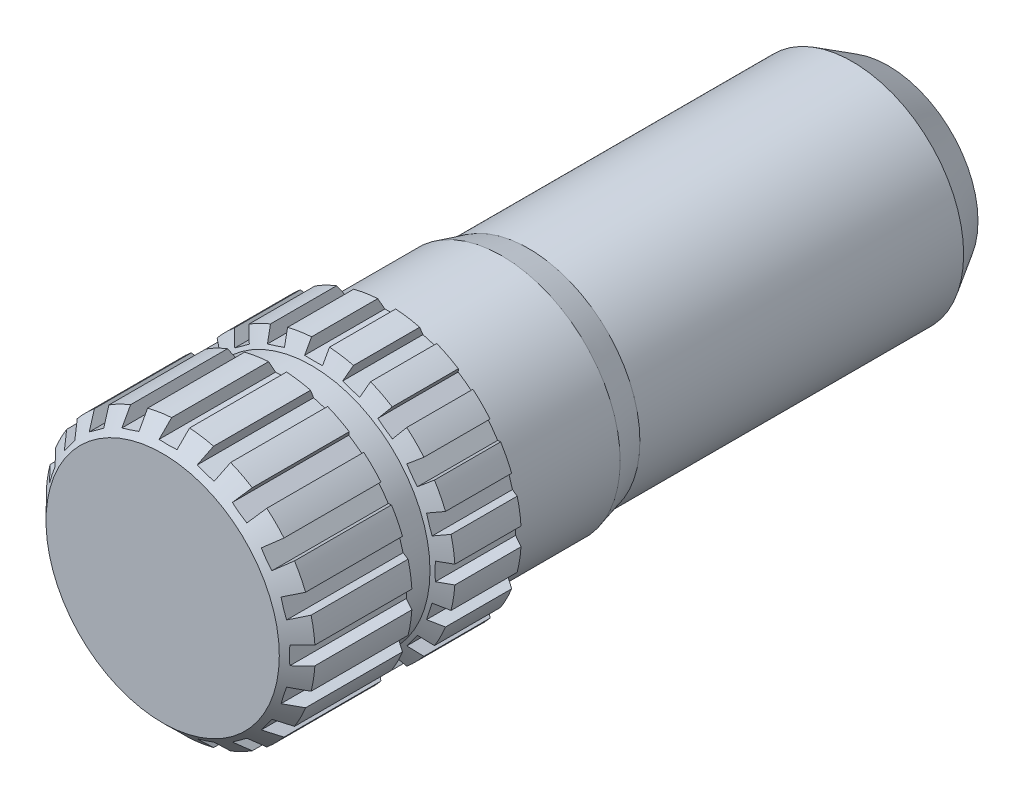
from build123d import *

# Parameters (mm, degrees)
CHAMFER1_SIZE      = 1.27
SKETCH2_OUTSIDE_W  = 32.648
SKETCH2_OUTSIDE_H  = 32.648
CUT_EXTRUDE1_DEPTH = 52.347959


with BuildPart() as part:
    # Sketch1 → Revolve1 (revolve)
    with BuildSketch(Plane(origin=(0, 0, 0), x_dir=(0, 0, -1), z_dir=(1, 0, 0))):
        Polygon((-33.567959, 0), (-33.567959, 9.525), (-25.436281885, 9.525), (-24.801281885, 8.382), (-23.030636116, 8.382), (-22.395636116, 9.525), (-17.713279, 9.525), (-17.057959, 8.382), (-9.573838806, 8.382), (-7.668838806, 7.874), (15.24, 7.874), (17.78, 6.35), (17.78, 0), align=None)
    revolve(axis=Axis((0, 0, -0.29154961), (0, 0, 1)))

    # Chamfer1
    chamfer1_edges = [part.edges().sort_by_distance(p)[0] for p in [
        (0, -9.525, 33.567959),
    ]]
    chamfer(chamfer1_edges, length=CHAMFER1_SIZE)

    # Sketch2 outside → Cut-Extrude1 (cut, through all)
    with BuildSketch(Plane.XY.offset(33.567959)):
        Rectangle(SKETCH2_OUTSIDE_W, SKETCH2_OUTSIDE_H)
        with BuildLine():
            Line((-0.635, 8.614809762), (0.635, 8.614809762))
            Line((0.635, 8.614809762), (0.635, 9.503809762))
            ThreePointArc((0.635, 9.503809762), (1.49003828, 9.407731444), (2.33291784, 9.234885996))
            Line((2.33291784, 9.234885996), (2.058201732, 8.389396753))
            Line((2.058201732, 8.389396753), (3.266043508, 7.99694517))
            Line((3.266043508, 7.99694517), (3.540759616, 8.842434413))
            ThreePointArc((3.540759616, 8.842434413), (4.32425951, 8.486837143), (5.072473428, 8.061987244))
            Line((5.072473428, 8.061987244), (4.549932338, 7.342771136))
            Line((4.549932338, 7.342771136), (5.577383921, 6.596283866))
            Line((5.577383921, 6.596283866), (6.09992501, 7.315499974))
            ThreePointArc((6.09992501, 7.315499974), (6.735192091, 6.735192091), (7.315499974, 6.09992501))
            Line((7.315499974, 6.09992501), (6.596283866, 5.577383921))
            Line((6.596283866, 5.577383921), (7.342771136, 4.549932338))
            Line((7.342771136, 4.549932338), (8.061987244, 5.072473428))
            ThreePointArc((8.061987244, 5.072473428), (8.486837143, 4.32425951), (8.842434413, 3.540759616))
            Line((8.842434413, 3.540759616), (7.99694517, 3.266043508))
            Line((7.99694517, 3.266043508), (8.389396753, 2.058201732))
            Line((8.389396753, 2.058201732), (9.234885996, 2.33291784))
            ThreePointArc((9.234885996, 2.33291784), (9.407731444, 1.49003828), (9.503809762, 0.635))
            Line((9.503809762, 0.635), (8.614809762, 0.635))
            Line((8.614809762, 0.635), (8.614809762, -0.635))
            Line((8.614809762, -0.635), (9.503809762, -0.635))
            ThreePointArc((9.503809762, -0.635), (9.407731444, -1.49003828), (9.234885996, -2.33291784))
            Line((9.234885996, -2.33291784), (8.389396753, -2.058201732))
            Line((8.389396753, -2.058201732), (7.99694517, -3.266043508))
            Line((7.99694517, -3.266043508), (8.842434413, -3.540759616))
            ThreePointArc((8.842434413, -3.540759616), (8.486837143, -4.32425951), (8.061987244, -5.072473428))
            Line((8.061987244, -5.072473428), (7.342771136, -4.549932338))
            Line((7.342771136, -4.549932338), (6.596283866, -5.577383921))
            Line((6.596283866, -5.577383921), (7.315499974, -6.09992501))
            ThreePointArc((7.315499974, -6.09992501), (6.735192091, -6.735192091), (6.09992501, -7.315499974))
            Line((6.09992501, -7.315499974), (5.577383921, -6.596283866))
            Line((5.577383921, -6.596283866), (4.549932338, -7.342771136))
            Line((4.549932338, -7.342771136), (5.072473428, -8.061987244))
            ThreePointArc((5.072473428, -8.061987244), (4.32425951, -8.486837143), (3.540759616, -8.842434413))
            Line((3.540759616, -8.842434413), (3.266043508, -7.99694517))
            Line((3.266043508, -7.99694517), (2.058201732, -8.389396753))
            Line((2.058201732, -8.389396753), (2.33291784, -9.234885996))
            ThreePointArc((2.33291784, -9.234885996), (1.49003828, -9.407731444), (0.635, -9.503809762))
            Line((0.635, -9.503809762), (0.635, -8.614809762))
            Line((0.635, -8.614809762), (-0.635, -8.614809762))
            Line((-0.635, -8.614809762), (-0.635, -9.503809762))
            ThreePointArc((-0.635, -9.503809762), (-1.49003828, -9.407731444), (-2.33291784, -9.234885996))
            Line((-2.33291784, -9.234885996), (-2.058201732, -8.389396753))
            Line((-2.058201732, -8.389396753), (-3.266043508, -7.99694517))
            Line((-3.266043508, -7.99694517), (-3.540759616, -8.842434413))
            ThreePointArc((-3.540759616, -8.842434413), (-4.32425951, -8.486837143), (-5.072473428, -8.061987244))
            Line((-5.072473428, -8.061987244), (-4.549932338, -7.342771136))
            Line((-4.549932338, -7.342771136), (-5.577383921, -6.596283866))
            Line((-5.577383921, -6.596283866), (-6.09992501, -7.315499974))
            ThreePointArc((-6.09992501, -7.315499974), (-6.735192091, -6.735192091), (-7.315499974, -6.09992501))
            Line((-7.315499974, -6.09992501), (-6.596283866, -5.577383921))
            Line((-6.596283866, -5.577383921), (-7.342771136, -4.549932338))
            Line((-7.342771136, -4.549932338), (-8.061987244, -5.072473428))
            ThreePointArc((-8.061987244, -5.072473428), (-8.486837143, -4.32425951), (-8.842434413, -3.540759616))
            Line((-8.842434413, -3.540759616), (-7.99694517, -3.266043508))
            Line((-7.99694517, -3.266043508), (-8.389396753, -2.058201732))
            Line((-8.389396753, -2.058201732), (-9.234885996, -2.33291784))
            ThreePointArc((-9.234885996, -2.33291784), (-9.407731444, -1.49003828), (-9.503809762, -0.635))
            Line((-9.503809762, -0.635), (-8.614809762, -0.635))
            Line((-8.614809762, -0.635), (-8.614809762, 0.635))
            Line((-8.614809762, 0.635), (-9.503809762, 0.635))
            ThreePointArc((-9.503809762, 0.635), (-9.407731444, 1.49003828), (-9.234885996, 2.33291784))
            Line((-9.234885996, 2.33291784), (-8.389396753, 2.058201732))
            Line((-8.389396753, 2.058201732), (-7.99694517, 3.266043508))
            Line((-7.99694517, 3.266043508), (-8.842434413, 3.540759616))
            ThreePointArc((-8.842434413, 3.540759616), (-8.486837143, 4.32425951), (-8.061987244, 5.072473428))
            Line((-8.061987244, 5.072473428), (-7.342771136, 4.549932338))
            Line((-7.342771136, 4.549932338), (-6.596283866, 5.577383921))
            Line((-6.596283866, 5.577383921), (-7.315499974, 6.09992501))
            ThreePointArc((-7.315499974, 6.09992501), (-6.735192091, 6.735192091), (-6.09992501, 7.315499974))
            Line((-6.09992501, 7.315499974), (-5.577383921, 6.596283866))
            Line((-5.577383921, 6.596283866), (-4.549932338, 7.342771136))
            Line((-4.549932338, 7.342771136), (-5.072473428, 8.061987244))
            ThreePointArc((-5.072473428, 8.061987244), (-4.32425951, 8.486837143), (-3.540759616, 8.842434413))
            Line((-3.540759616, 8.842434413), (-3.266043508, 7.99694517))
            Line((-3.266043508, 7.99694517), (-2.058201732, 8.389396753))
            Line((-2.058201732, 8.389396753), (-2.33291784, 9.234885996))
            ThreePointArc((-2.33291784, 9.234885996), (-1.49003828, 9.407731444), (-0.635, 9.503809762))
            Line((-0.635, 9.503809762), (-0.635, 8.614809762))
        make_face(mode=Mode.SUBTRACT)
    extrude(amount=-CUT_EXTRUDE1_DEPTH, mode=Mode.SUBTRACT)


solid = part.part
